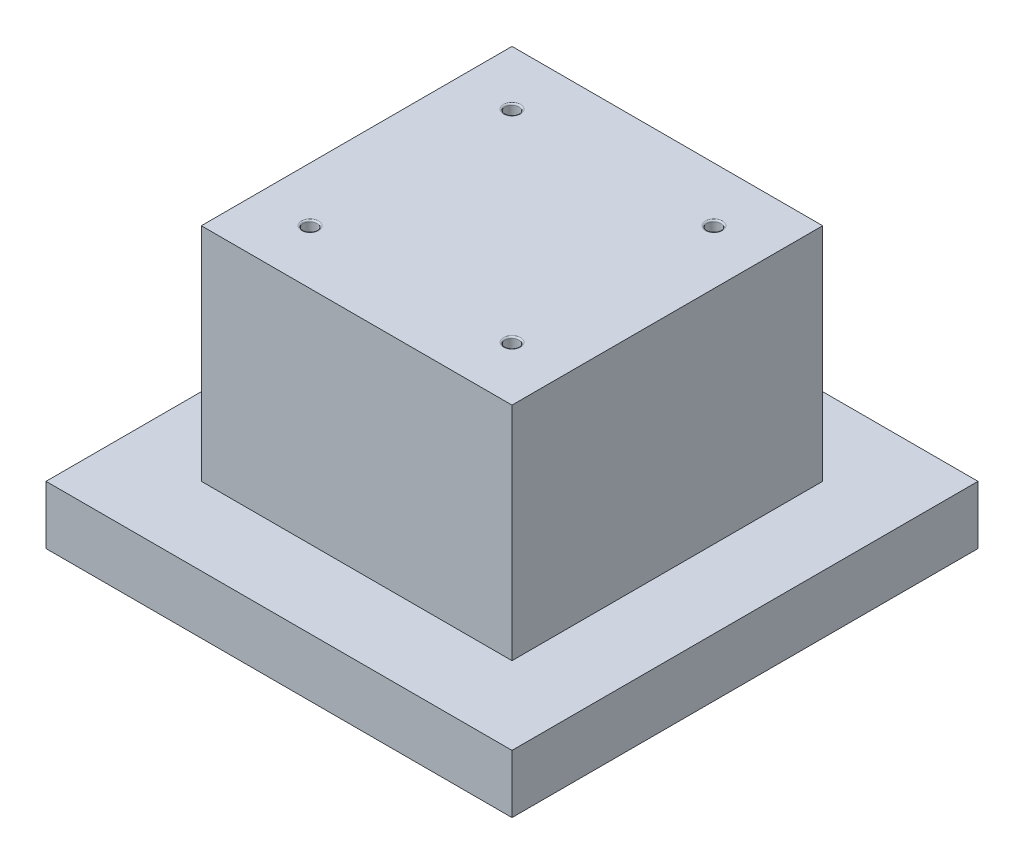
from build123d import *

# Parameters (mm, degrees)
SKETCH1_W                 = 76.2
SKETCH1_H                 = 76.2
EXTRUDE1_DEPTH            = 9.525
SKETCH2_W                 = 68.58
SKETCH2_H                 = 68.58
EXTRUDE2_DEPTH            = 0.79375
SKETCH6_W                 = 50.8
SKETCH6_H                 = 50.8
EXTRUDE4_DEPTH            = 36.195
F_4_40_TAPPED_HOLE1_D     = 2.2606
F_4_40_TAPPED_HOLE1_DEPTH = 12.7
F_4_40_TAPPED_HOLE1_TIP   = 0.679152758
FILLET1_R                 = 0.254


with BuildPart() as part:
    # Sketch1 → Extrude1 (new body)
    with BuildSketch(Plane(origin=(0, 0, 0), x_dir=(1, 0, 0), z_dir=(0, 1, 0))):
        Rectangle(SKETCH1_W, SKETCH1_H)
    extrude(amount=EXTRUDE1_DEPTH)

    # Sketch2 → Extrude2 (cut)
    with BuildSketch(Plane.XZ):
        Rectangle(SKETCH2_W, SKETCH2_H)
    extrude(amount=-EXTRUDE2_DEPTH, mode=Mode.SUBTRACT)

    # Sketch6 → Extrude4 (add)
    with BuildSketch(Plane(origin=(0, 9.525, 0), x_dir=(1, 0, 0), z_dir=(0, 1, 0))):
        Rectangle(SKETCH6_W, SKETCH6_H)
    extrude(amount=EXTRUDE4_DEPTH)

    # #4-40 Tapped Hole1
    with Locations(Plane(origin=(-16.51, 45.72, -16.51), x_dir=(0, 0, 1), z_dir=(0, 1, 0))):
        with Locations((0, 0), (33.02, 0), (33.02, 33.02), (0, 33.02)):
            Hole(F_4_40_TAPPED_HOLE1_D / 2, depth=F_4_40_TAPPED_HOLE1_DEPTH)
            with Locations((0, 0, -(F_4_40_TAPPED_HOLE1_DEPTH + F_4_40_TAPPED_HOLE1_TIP / 2))):  # 118° drill point
                Cone(0, F_4_40_TAPPED_HOLE1_D / 2, F_4_40_TAPPED_HOLE1_TIP, mode=Mode.SUBTRACT)

    # Fillet1
    fillet1_edges = [part.edges().sort_by_distance(p)[0] for p in [
        (16.51, 45.72, -15.3797),
        (16.51, 45.72, 17.6403),
        (-16.51, 45.72, 17.6403),
        (-16.51, 45.72, -15.3797),
    ]]
    fillet(fillet1_edges, radius=FILLET1_R)


solid = part.part
